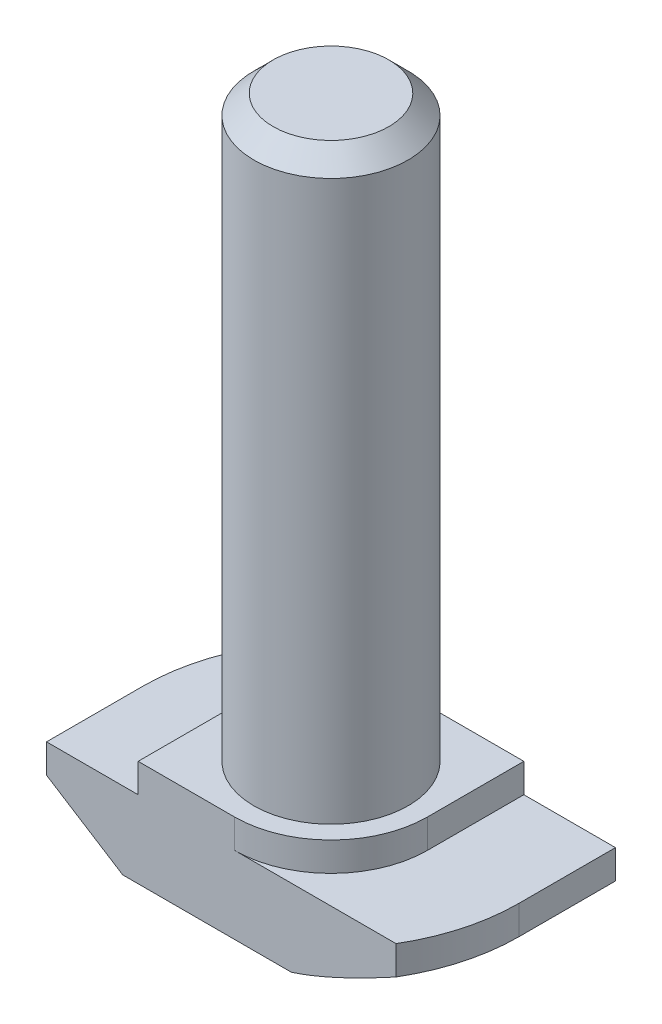
from build123d import *

# Parameters (mm, degrees)
EXTRUDE_1_DEPTH     = 5
CUT_EXTRUDE_1_DEPTH = 1.5
SKETCH_2_R          = 4
EXTRUDE_2_DEPTH     = 30
CUT_EXTRUDE_2_DEPTH = 5
CHAMFER_2_SIZE      = 1


with BuildPart() as part:
    # Эскиз1 → Бобышка-Вытянуть1 (new body, symmetric)
    with BuildSketch(Plane.XY):
        Polygon((9.75, 0), (-9.75, 0), (-9.75, 4), (-5, 4), (-5, 5.5), (5, 5.5), (5, 4), (9.75, 4), align=None)
    extrude(amount=EXTRUDE_1_DEPTH, both=True)

    # Эскиз3 → Вырез-Вытянуть1 (cut)
    with BuildSketch(Plane(origin=(0, 5.5, 0), x_dir=(1, 0, 0), z_dir=(0, 1, 0))):
        with BuildLine():
            Line((-5, 0), (-5, 5))
            Line((-5, 5), (0, 5))
            ThreePointArc((0, 5), (-3.535533906, 3.535533906), (-5, 0))
        make_face()
        with BuildLine():
            Line((0, -5), (5, -5))
            Line((5, -5), (5, 0))
            ThreePointArc((5, 0), (3.535533906, -3.535533906), (0, -5))
        make_face()
    extrude(amount=-CUT_EXTRUDE_1_DEPTH, mode=Mode.SUBTRACT)

    # Эскиз2 → Бобышка-Вытянуть2 (add)
    with BuildSketch(Plane(origin=(0, 5.5, 0), x_dir=(1, 0, 0), z_dir=(0, 1, 0))):
        with Locations(Location((0, 0, 0), (0, 0, 270))):  # turned: the seam where the file's is
            Circle(SKETCH_2_R)
    extrude(amount=EXTRUDE_2_DEPTH)

    # Эскиз4 → Вырез-Вытянуть2 (cut, through all)
    with BuildSketch(Plane(origin=(0, 4, 0), x_dir=(1, 0, 0), z_dir=(0, 1, 0))):
        with BuildLine():
            Line((-8.370334521, 5), (-9.75, 5))
            Line((-9.75, 5), (-9.75, 0))
            ThreePointArc((-9.75, 0), (-9.398756875, 2.59342808), (-8.370334521, 5))
        make_face()
        with BuildLine():
            Line((8.370334521, -5), (9.75, -5))
            Line((9.75, -5), (9.75, 0))
            ThreePointArc((9.75, 0), (9.398756875, -2.59342808), (8.370334521, -5))
        make_face()
    extrude(amount=-CUT_EXTRUDE_2_DEPTH, mode=Mode.SUBTRACT)

    # Вырез-По траектории1: sweep along a path in Эскиз6
    with BuildLine(Plane.XZ) as sweep_1_path:
        Line((0, -9.75), (9.75, -9.75))
        Line((9.75, -9.75), (9.75, 0))
        ThreePointArc((9.75, 0), (6.894291117, 6.894291117), (0, 9.75))
        Line((0, 9.75), (-9.75, 9.75))
        Line((-9.75, 9.75), (-9.75, 0))
        ThreePointArc((-9.75, 0), (-6.894291117, -6.894291117), (0, -9.75))
    # Эскиз5 → Вырез-По траектории1 (sweep, cut)
    with BuildSketch(Plane.XY.offset(5)):
        Polygon((-9.75, 2.5), (-5.8, 0), (-9.75, 0), align=None)
    sweep(path=sweep_1_path.line, transition=Transition.RIGHT, mode=Mode.SUBTRACT)

    # Фаска2
    chamfer_2_edges = [part.edges().sort_by_distance(p)[0] for p in [
        (0, 35.5, -4),
    ]]
    chamfer(chamfer_2_edges, length=CHAMFER_2_SIZE)


solid = part.part
